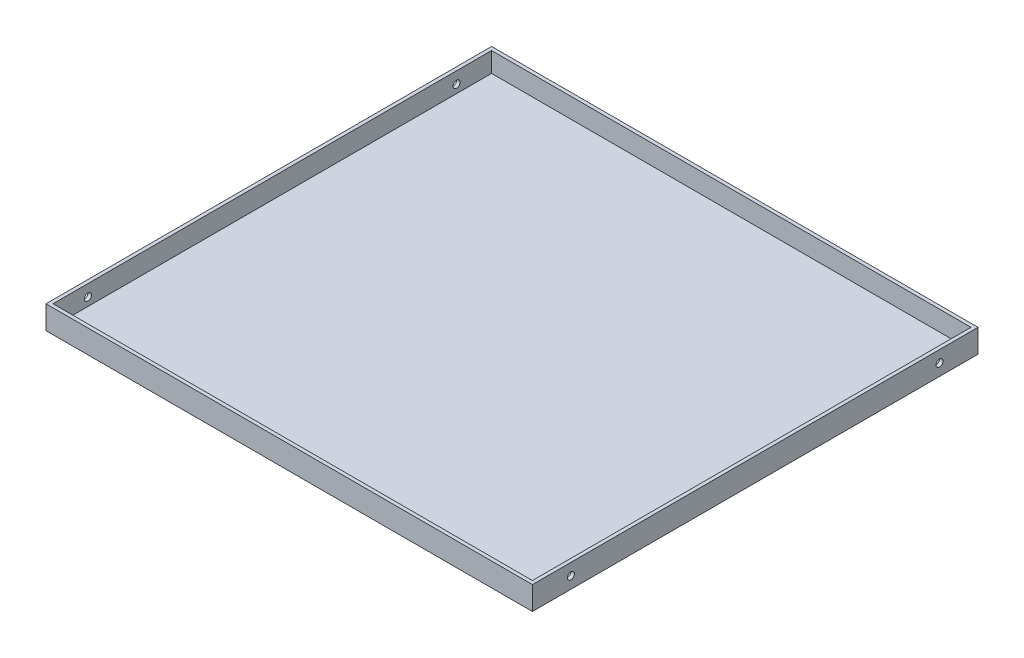
from build123d import *

# Parameters (mm, degrees)
SKETCH_1_W          = 417
SKETCH_1_H          = 382
EXTRUDE_3_DEPTH     = 20
SKETCH_2_W          = 411
SKETCH_2_H          = 376
CUT_EXTRUDE_1_DEPTH = 17
SKETCH_3_R          = 3
CUT_EXTRUDE_2_DEPTH = 418


with BuildPart() as part:
    # 草圖1 → 填料-伸長3 (new body)
    with BuildSketch(Plane(origin=(0, 0, 0), x_dir=(1, 0, 0), z_dir=(0, 1, 0))):
        with Locations((208.5, -191)):
            Rectangle(SKETCH_1_W, SKETCH_1_H)
    extrude(amount=EXTRUDE_3_DEPTH)

    # 草圖2 → 除料-伸長1 (cut)
    with BuildSketch(Plane(origin=(0, 20, 0), x_dir=(1, 0, 0), z_dir=(0, 1, 0))):
        with Locations((208.5, -191)):
            Rectangle(SKETCH_2_W, SKETCH_2_H)
    extrude(amount=-CUT_EXTRUDE_1_DEPTH, mode=Mode.SUBTRACT)

    # 草圖3 → 除料-伸長2 (cut, through all)
    with BuildSketch(Plane(origin=(417, 0, 0), x_dir=(0, 0, -1), z_dir=(1, 0, 0))):
        with Locations((-33, 10)):
            Circle(SKETCH_3_R)
        with Locations((-349, 10)):
            Circle(SKETCH_3_R)
    extrude(amount=-CUT_EXTRUDE_2_DEPTH, mode=Mode.SUBTRACT)


solid = part.part
